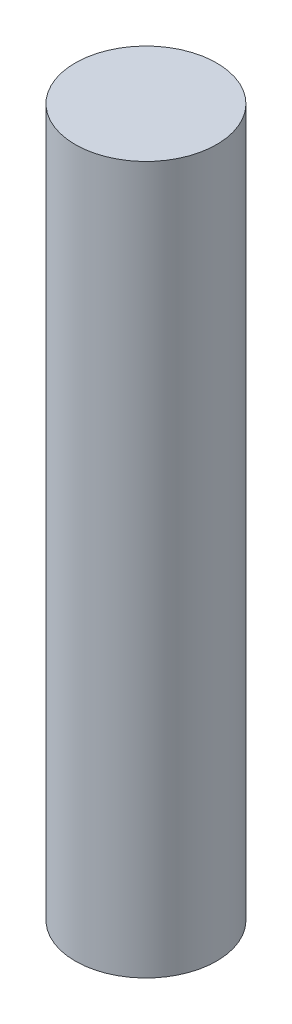
from build123d import *

# Parameters (mm, degrees)
SKETCH1_R           = 45
BOSS_EXTRUDE1_DEPTH = 450


with BuildPart() as part:
    # Sketch1 → Boss-Extrude1 (new body)
    with BuildSketch(Plane(origin=(0, 0, 0), x_dir=(1, 0, 0), z_dir=(0, 1, 0))):
        Circle(SKETCH1_R)
    extrude(amount=BOSS_EXTRUDE1_DEPTH)


solid = part.part
